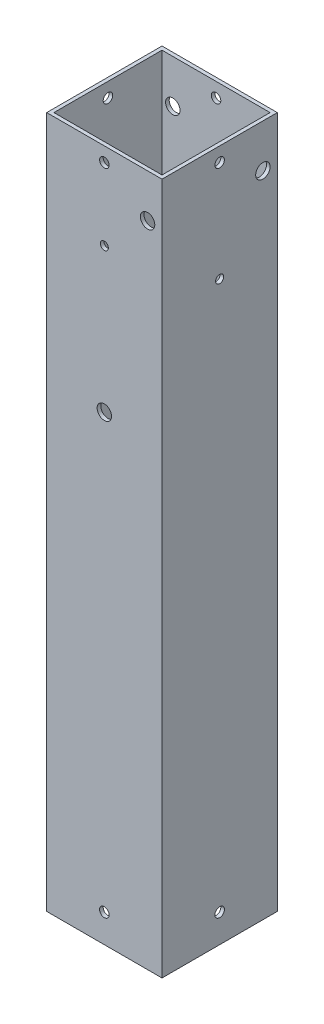
from build123d import *

# Parameters (mm, degrees)
SKETCH1_W               = 50.8
SKETCH1_H               = 50.8
SKETCH1_W_2             = 47.625
SKETCH1_H_2             = 47.625
BOSS_EXTRUDE1_DEPTH     = 304.8
SKETCH6_R               = 2.0955
CUT_EXTRUDE3_DEPTH      = 1
CUT_EXTRUDE3_DEPTH_BACK = 51.8
SKETCH7_R               = 2.0955
CUT_EXTRUDE4_DEPTH      = 1
CUT_EXTRUDE4_DEPTH_BACK = 51.8
SKETCH8_R               = 2.0955
CUT_EXTRUDE5_DEPTH      = 51.8
SKETCH9_R               = 2.0955
CUT_EXTRUDE6_DEPTH      = 51.8
SKETCH10_R              = 3.175
CUT_EXTRUDE7_DEPTH      = 5.08
SKETCH11_R              = 3.175
CUT_EXTRUDE8_DEPTH      = 5.08
SKETCH12_R              = 3.175
CUT_EXTRUDE9_DEPTH      = 5.08
SKETCH13_R              = 3.175
CUT_EXTRUDE10_DEPTH     = 5.08
SKETCH15_R              = 1.778
SKETCH15_R_2            = 3.175
CUT_EXTRUDE12_DEPTH     = 5.08
SKETCH16_R              = 1.778
CUT_EXTRUDE13_DEPTH     = 5.08
SKETCH17_R              = 1.778
CUT_EXTRUDE14_DEPTH     = 5.08
SKETCH19_R              = 1.778
SKETCH19_R_2            = 3.175
CUT_EXTRUDE15_DEPTH     = 5.08


with BuildPart() as part:
    # Sketch1 → Boss-Extrude1 (new body)
    with BuildSketch(Plane(origin=(0, 0, 0), x_dir=(1, 0, 0), z_dir=(0, 1, 0))):
        Rectangle(SKETCH1_W, SKETCH1_H)
        Rectangle(SKETCH1_W_2, SKETCH1_H_2, mode=Mode.SUBTRACT)
    extrude(amount=BOSS_EXTRUDE1_DEPTH)

    # Sketch6 → Cut-Extrude3 (cut, two sides)
    with BuildSketch(Plane(origin=(25.4, 0, 0), x_dir=(0, 0, -1), z_dir=(1, 0, 0))) as cut_extrude3_sk:
        with Locations((0, 12.412400118)):
            Circle(SKETCH6_R)
    extrude(amount=CUT_EXTRUDE3_DEPTH, mode=Mode.SUBTRACT)
    extrude(cut_extrude3_sk.sketch, amount=-CUT_EXTRUDE3_DEPTH_BACK, mode=Mode.SUBTRACT)

    # Sketch7 → Cut-Extrude4 (cut, two sides)
    with BuildSketch(Plane(origin=(0, 0, -25.4), x_dir=(-1, 0, 0), z_dir=(0, 0, -1))) as cut_extrude4_sk:
        with Locations((0, 12.412400118)):
            Circle(SKETCH7_R)
    extrude(amount=CUT_EXTRUDE4_DEPTH, mode=Mode.SUBTRACT)
    extrude(cut_extrude4_sk.sketch, amount=-CUT_EXTRUDE4_DEPTH_BACK, mode=Mode.SUBTRACT)

    # Sketch8 → Cut-Extrude5 (cut, through all)
    with BuildSketch(Plane(origin=(25.4, 0, 0), x_dir=(0, 0, -1), z_dir=(1, 0, 0))):
        with Locations((0, 298.45)):
            Circle(SKETCH8_R)
    extrude(amount=-CUT_EXTRUDE5_DEPTH, mode=Mode.SUBTRACT)

    # Sketch9 → Cut-Extrude6 (cut, through all)
    with BuildSketch(Plane.XY.offset(25.4)):
        with Locations((0, 298.45)):
            Circle(SKETCH9_R)
    extrude(amount=-CUT_EXTRUDE6_DEPTH, mode=Mode.SUBTRACT)

    # Sketch10 → Cut-Extrude7 (cut)
    with BuildSketch(Plane.XY.offset(25.4)):
        with Locations((19.05, 285.75)):
            Circle(SKETCH10_R)
    extrude(amount=-CUT_EXTRUDE7_DEPTH, mode=Mode.SUBTRACT)

    # Sketch11 → Cut-Extrude8 (cut)
    with BuildSketch(Plane.ZY.offset(25.4)):
        with Locations((19.05, 285.75)):
            Circle(SKETCH11_R)
    extrude(amount=-CUT_EXTRUDE8_DEPTH, mode=Mode.SUBTRACT)

    # Sketch12 → Cut-Extrude9 (cut)
    with BuildSketch(Plane(origin=(0, 0, -25.4), x_dir=(-1, 0, 0), z_dir=(0, 0, -1))):
        with Locations((19.05, 285.75)):
            Circle(SKETCH12_R)
    extrude(amount=-CUT_EXTRUDE9_DEPTH, mode=Mode.SUBTRACT)

    # Sketch13 → Cut-Extrude10 (cut)
    with BuildSketch(Plane(origin=(25.4, 0, 0), x_dir=(0, 0, -1), z_dir=(1, 0, 0))):
        with Locations((19.05, 285.75)):
            Circle(SKETCH13_R)
    extrude(amount=-CUT_EXTRUDE10_DEPTH, mode=Mode.SUBTRACT)

    # Sketch15 → Cut-Extrude12 (cut)
    with BuildSketch(Plane(origin=(0, 0, -25.4), x_dir=(-1, 0, 0), z_dir=(0, 0, -1))):
        with Locations((0, 222.25)):
            Circle(SKETCH15_R)
        with Locations((0, 190.5)):
            Circle(SKETCH15_R_2)
    extrude(amount=-CUT_EXTRUDE12_DEPTH, mode=Mode.SUBTRACT)

    # Sketch16 → Cut-Extrude13 (cut)
    with BuildSketch(Plane(origin=(25.4, 0, 0), x_dir=(0, 0, -1), z_dir=(1, 0, 0))):
        with Locations((0, 254)):
            Circle(SKETCH16_R)
    extrude(amount=-CUT_EXTRUDE13_DEPTH, mode=Mode.SUBTRACT)

    # Sketch17 → Cut-Extrude14 (cut)
    with BuildSketch(Plane.ZY.offset(25.4)):
        with Locations((0, 203.2)):
            Circle(SKETCH17_R)
    extrude(amount=-CUT_EXTRUDE14_DEPTH, mode=Mode.SUBTRACT)

    # Sketch19 → Cut-Extrude15 (cut)
    with BuildSketch(Plane.XY.offset(25.4)):
        with Locations((0, 266.7)):
            Circle(SKETCH19_R)
        with Locations((0, 203.2)):
            Circle(SKETCH19_R_2)
    extrude(amount=-CUT_EXTRUDE15_DEPTH, mode=Mode.SUBTRACT)


solid = part.part
